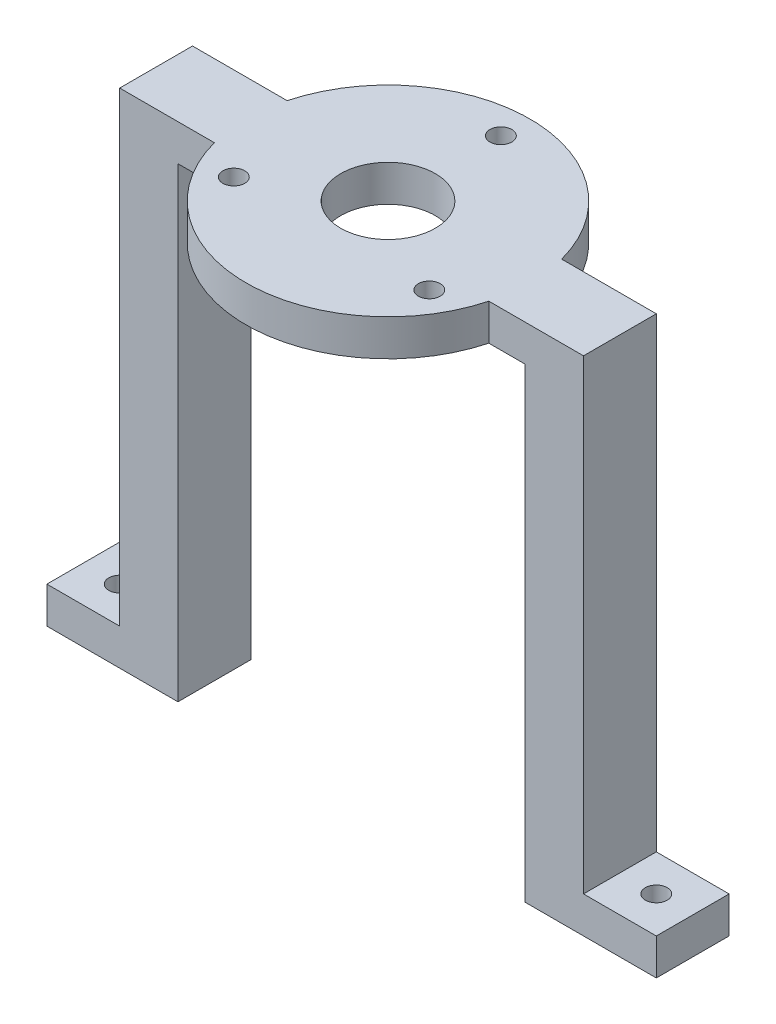
from build123d import *

# Parameters (mm, degrees)
SKETCH1_R                 = 6.5
BOSS_EXTRUDE1_DEPTH       = 5
SKETCH2_W                 = 8
SKETCH2_H                 = 10
BOSS_EXTRUDE2_DEPTH       = 64
SKETCH5_W                 = 10
SKETCH5_H                 = 5
BOSS_EXTRUDE3_DEPTH       = 10
SKETCH6_W                 = 10
SKETCH6_H                 = 5
BOSS_EXTRUDE4_DEPTH       = 10
F_3_0MM_DOWEL_HOLE1_D     = 3
F_3_0MM_DOWEL_HOLE1_DEPTH = 23
F_3_0MM_DOWEL_HOLE1_TIP   = 0.901290929
F_3_0MM_DOWEL_HOLE2_D     = 3


with BuildPart() as part:
    # Sketch1 → Boss-Extrude1 (new body)
    with BuildSketch(Plane(origin=(0, 0, 0), x_dir=(1, 0, 0), z_dir=(0, 1, 0))):
        with BuildLine():
            Line((-31.848076825, -5), (-18.848076825, -5))
            ThreePointArc((-18.848076825, -5), (0, -19.5), (18.848076825, -5))
            Line((18.848076825, -5), (31.848076825, -5))
            Line((31.848076825, -5), (31.848076825, 5))
            Line((31.848076825, 5), (18.848076825, 5))
            ThreePointArc((18.848076825, 5), (0, 19.5), (-18.848076825, 5))
            Line((-18.848076825, 5), (-31.848076825, 5))
            Line((-31.848076825, 5), (-31.848076825, -5))
        make_face()
        Circle(SKETCH1_R, mode=Mode.SUBTRACT)
    extrude(amount=BOSS_EXTRUDE1_DEPTH)

    # Sketch2 → Boss-Extrude2 (add)
    with BuildSketch(Plane.XZ):
        with Locations((-27.848076825, 0)):
            Rectangle(SKETCH2_W, SKETCH2_H)
        with Locations((27.848076825, 0)):
            Rectangle(SKETCH2_W, SKETCH2_H)
    extrude(amount=BOSS_EXTRUDE2_DEPTH)

    # Sketch5 → Boss-Extrude3 (add)
    with BuildSketch(Plane.ZY.offset(31.848076825)):
        with Locations((0, -61.5)):
            Rectangle(SKETCH5_W, SKETCH5_H)
    extrude(amount=BOSS_EXTRUDE3_DEPTH)

    # Sketch6 → Boss-Extrude4 (add)
    with BuildSketch(Plane(origin=(31.848076825, 0, 0), x_dir=(0, 0, -1), z_dir=(1, 0, 0))):
        with Locations((0, -61.5)):
            Rectangle(SKETCH6_W, SKETCH6_H)
    extrude(amount=BOSS_EXTRUDE4_DEPTH)

    # Ø3.0mm Dowel Hole1
    with Locations(Plane(origin=(0, -59, 0), x_dir=(1, 0, 0), z_dir=(0, 1, 0))):
        with Locations((36.848076825, 0), (-36.848076825, 0)):
            Hole(F_3_0MM_DOWEL_HOLE1_D / 2, depth=F_3_0MM_DOWEL_HOLE1_DEPTH)
            with Locations((0, 0, -(F_3_0MM_DOWEL_HOLE1_DEPTH + F_3_0MM_DOWEL_HOLE1_TIP / 2))):  # 118° drill point
                Cone(0, F_3_0MM_DOWEL_HOLE1_D / 2, F_3_0MM_DOWEL_HOLE1_TIP, mode=Mode.SUBTRACT)

    # Ø3.0mm Dowel Hole2 (through all)
    with Locations(Plane(origin=(0, 5, 0), x_dir=(1, 0, 0), z_dir=(0, 1, 0))):
        with Locations((0, 15.5), (13.423393759, -7.75), (-13.423393759, -7.75)):
            Hole(F_3_0MM_DOWEL_HOLE2_D / 2)


solid = part.part
